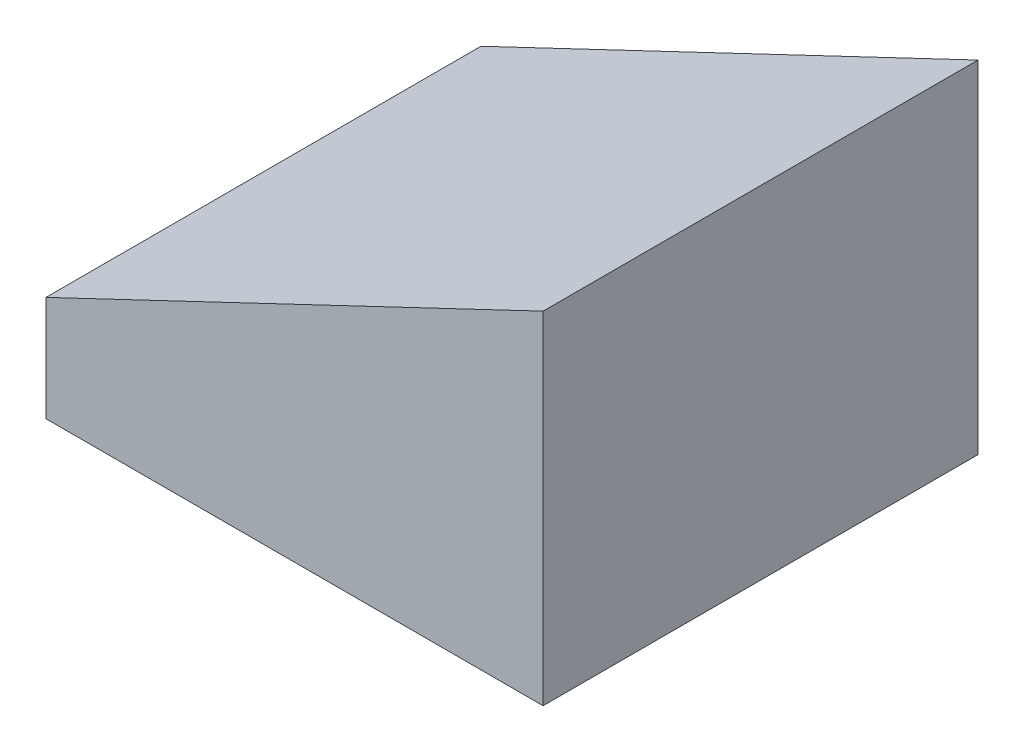
from build123d import *

# Parameters (mm, degrees)
SKETCH1_W                       = 10.16
SKETCH1_H                       = 3.175
BOSS_EXTRUDE1_DEPTH             = 4.445
SKETCH3_OUTSIDE_W               = 14.934
SKETCH3_OUTSIDE_H               = 13.664
SKETCH3_OUTSIDE_W_2             = 10.16
SKETCH3_OUTSIDE_H_2             = 8.89
SKETCH3_OUTSIDE_W_3             = 5.08
SKETCH3_OUTSIDE_H_3             = 5.08
CUT_EXTRUDE1_DEPTH              = 1.905
BOSS_EXTRUDE2_REACH             = 6.445
BOSS_EXTRUDE2_DIRECTION_2_REACH = 6.445
CUT_EXTRUDE3_DEPTH              = 5.445
CUT_EXTRUDE3_DEPTH_BACK         = 5.445


with BuildPart() as part:
    # Sketch1 → Boss-Extrude1 (new body, symmetric)
    with BuildSketch(Plane.XY):
        with Locations((0, -1.5875)):
            Rectangle(SKETCH1_W, SKETCH1_H)
    extrude(amount=BOSS_EXTRUDE1_DEPTH, both=True)

    # Sketch3 outside → Cut-Extrude1 (cut)
    with BuildSketch(Plane.XZ.offset(3.175)):
        Rectangle(SKETCH3_OUTSIDE_W, SKETCH3_OUTSIDE_H)
        Rectangle(SKETCH3_OUTSIDE_W_2, SKETCH3_OUTSIDE_H_2, mode=Mode.SUBTRACT)
        Rectangle(SKETCH3_OUTSIDE_W_3, SKETCH3_OUTSIDE_H_3)
    extrude(amount=-CUT_EXTRUDE1_DEPTH, mode=Mode.SUBTRACT)

    # Boss-Extrude2: up to this face of the body (flat: up to its plane)
    boss_extrude2_end = Plane(part.part.faces().sort_by_distance((0, -1.5875, 4.445))[0])
    # Sketch5 → Boss-Extrude2 (add, up to the picked face)
    with BuildSketch(Plane.XY, mode=Mode.PRIVATE) as boss_extrude2_sk1:
        Polygon((-2.924444558, 0), (5.08, 3.81), (5.08, 0), align=None)
    boss_extrude2_tool1 = split(extrude(boss_extrude2_sk1.sketch, amount=BOSS_EXTRUDE2_REACH, mode=Mode.PRIVATE), bisect_by=boss_extrude2_end, keep=Keep.BOTH, mode=Mode.PRIVATE)
    add(boss_extrude2_tool1.solids().sort_by_distance((2.411852, 1.27, 0))[0])

    # Boss-Extrude2 direction 2: up to this face of the body (flat: up to its plane)
    boss_extrude2_direction_2_end = Plane(part.part.faces().sort_by_distance((0, -1.5875, -4.445))[0])
    # Sketch5 → Boss-Extrude2 direction 2 (add, up to the picked face)
    with BuildSketch(Plane.XY, mode=Mode.PRIVATE) as boss_extrude2_direction_2_sk1:
        Polygon((-2.924444558, 0), (5.08, 3.81), (5.08, 0), align=None)
    boss_extrude2_direction_2_tool1 = split(extrude(boss_extrude2_direction_2_sk1.sketch, amount=-BOSS_EXTRUDE2_DIRECTION_2_REACH, mode=Mode.PRIVATE), bisect_by=boss_extrude2_direction_2_end, keep=Keep.BOTH, mode=Mode.PRIVATE)
    add(boss_extrude2_direction_2_tool1.solids().sort_by_distance((2.411852, 1.27, 0))[0])

    # Sketch6 → Cut-Extrude3 (cut, two sides)
    with BuildSketch(Plane.XY) as cut_extrude3_sk:
        Polygon((-5.08, -1.026013257), (-5.08, 0), (-2.924444558, 0), align=None)
    extrude(amount=CUT_EXTRUDE3_DEPTH, mode=Mode.SUBTRACT)
    extrude(cut_extrude3_sk.sketch, amount=-CUT_EXTRUDE3_DEPTH_BACK, mode=Mode.SUBTRACT)


solid = part.part
